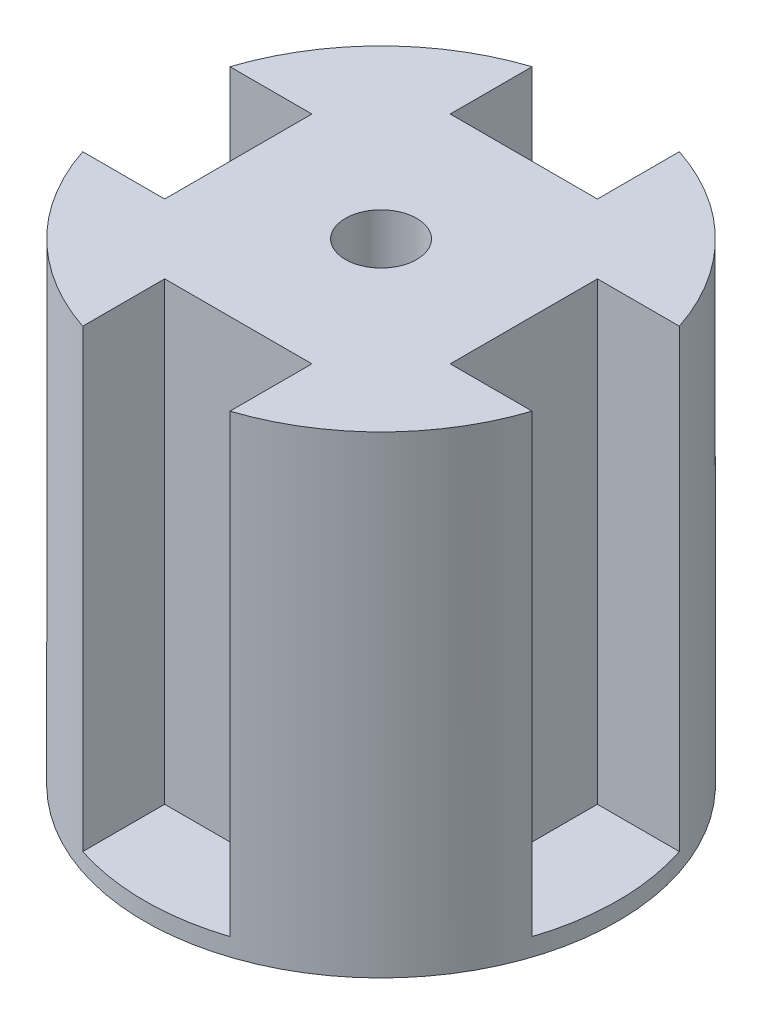
from build123d import *

# Parameters (mm, degrees)
BOSS_EXTRUDE1_DEPTH = 51
SKETCH3_R           = 26.5
BOSS_EXTRUDE2_DEPTH = 2
SKETCH4_R           = 4
CUT_EXTRUDE1_DEPTH  = 54


with BuildPart() as part:
    # Sketch2 → Boss-Extrude1 (new body)
    with BuildSketch(Plane(origin=(0, 0, 0), x_dir=(1, 0, 0), z_dir=(0, 1, 0))):
        with BuildLine():
            Line((-8.25, 25.183079637), (-8.25, 16))
            Line((-8.25, 16), (8.25, 16))
            Line((8.25, 16), (8.25, 25.183079637))
            ThreePointArc((8.25, 25.183079637), (18.738329701, 18.738329701), (25.183079637, 8.25))
            Line((25.183079637, 8.25), (16, 8.25))
            Line((16, 8.25), (16, -8.25))
            Line((16, -8.25), (25.183079637, -8.25))
            ThreePointArc((25.183079637, -8.25), (18.738329701, -18.738329701), (8.25, -25.183079637))
            Line((8.25, -25.183079637), (8.25, -16))
            Line((8.25, -16), (-8.25, -16))
            Line((-8.25, -16), (-8.25, -25.183079637))
            ThreePointArc((-8.25, -25.183079637), (-18.738329701, -18.738329701), (-25.183079637, -8.25))
            Line((-25.183079637, -8.25), (-16, -8.25))
            Line((-16, -8.25), (-16, 8.25))
            Line((-16, 8.25), (-25.183079637, 8.25))
            ThreePointArc((-25.183079637, 8.25), (-18.738329701, 18.738329701), (-8.25, 25.183079637))
        make_face()
    extrude(amount=BOSS_EXTRUDE1_DEPTH)

    # Sketch3 → Boss-Extrude2 (add)
    with BuildSketch(Plane.XZ):
        Circle(SKETCH3_R)
    extrude(amount=BOSS_EXTRUDE2_DEPTH)

    # Sketch4 → Cut-Extrude1 (cut, through all)
    with BuildSketch(Plane(origin=(0, 51, 0), x_dir=(1, 0, 0), z_dir=(0, 1, 0))):
        Circle(SKETCH4_R)
    extrude(amount=-CUT_EXTRUDE1_DEPTH, mode=Mode.SUBTRACT)


solid = part.part
